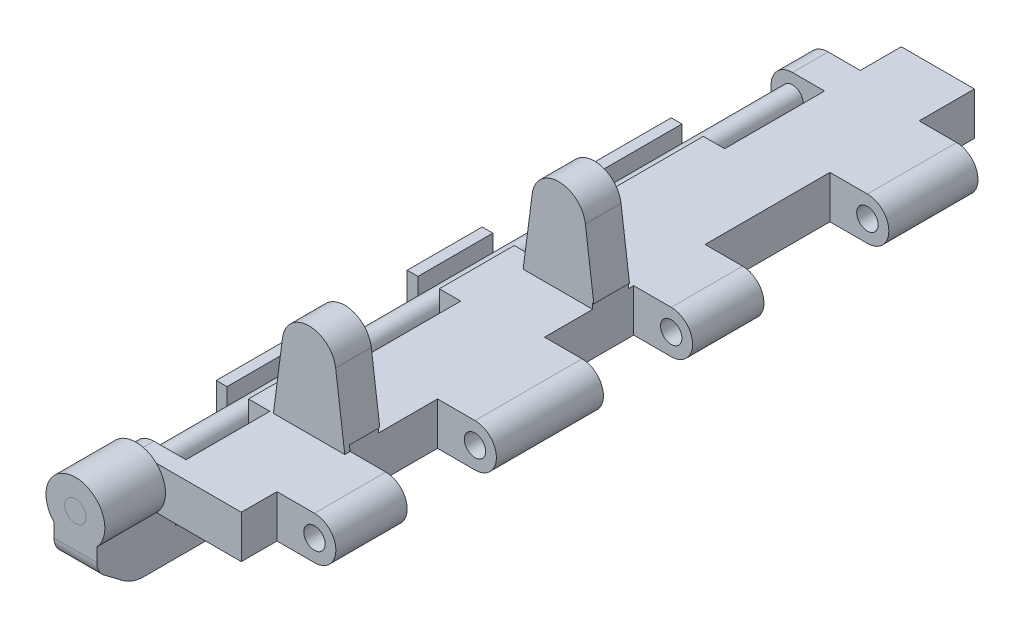
from build123d import *

# Parameters (mm, degrees)
SKETCH_1_R           = 0.6
EXTRUDE_1_DEPTH      = 41.1
SKETCH_2_W           = 5.7
SKETCH_2_H           = 5.25
SKETCH_2_W_2         = 12
SKETCH_2_W_3         = 19.4
CUT_EXTRUDE_1_DEPTH  = 9.75
CUT_EXTRUDE_START    = -1.2
SKETCH_6_W           = 4.7
SKETCH_6_H           = 3.5
SKETCH_6_W_2         = 6.5
SKETCH_6_W_3         = 4.6
SKETCH_6_W_4         = 5.6
SKETCH_6_W_5         = 2.3
CUT_EXTRUDE_4_DEPTH  = 3
CUT_EXTRUDE_5_DEPTH  = 3
CUT_EXTRUDE_START_2  = -36.8
CUT_EXTRUDE_6_DEPTH  = 3
CUT_EXTRUDE_START_3  = -5.7
SKETCH_11_W          = 1.2
SKETCH_11_H          = 1.2
CUT_EXTRUDE_7_DEPTH  = 27
SKETCH_12_W          = 3
SKETCH_12_H          = 4.320930259
SKETCH_12_W_2        = 2.5
CUT_EXTRUDE_8_DEPTH  = 3.5
SKETCH_13_W          = 3.3
SKETCH_13_H          = 2
SKETCH_13_H_2        = 5
SKETCH_13_H_3        = 7
SKETCH_13_H_4        = 3.1
CUT_EXTRUDE_9_DEPTH  = 1.5
SKETCH_14_R          = 1.65
SKETCH_14_R_2        = 0.6
EXTRUDE_2_DEPTH      = 3.4
CUT_EXTRUDE_10_DEPTH = 1.7
SKETCH_17_R          = 0.6
EXTRUDE_3_DEPTH      = 3.4
EXTRUDE_3_DEPTH_BACK = 38.8


with BuildPart() as part:
    # 草图1 → 凸台-拉伸1 (new body)
    with BuildSketch(Plane.XY):
        with BuildLine():
            Line((2, 1.2), (-1.2, 1.2))
            Line((-1.2, 1.2), (-1.2, -3.9))
            Line((-1.2, -3.9), (1.2, -3.9))
            Line((1.2, -3.9), (1.2, -1.2))
            Line((1.2, -1.2), (8, -1.2))
            ThreePointArc((8, -1.2), (9.2, 0), (8, 1.2))
            Line((8, 1.2), (6, 1.2))
            Line((6, 1.2), (5.487489304, 5.143327629))
            ThreePointArc((5.487489304, 5.143327629), (4, 6.45), (2.512510696, 5.143327629))
            Line((2.512510696, 5.143327629), (2, 1.2))
        make_face()
        Circle(SKETCH_1_R, mode=Mode.SUBTRACT)
        with Locations((8, 0)):
            Circle(SKETCH_1_R, mode=Mode.SUBTRACT)
    extrude(amount=-EXTRUDE_1_DEPTH)

    # 草图2 → 切除-拉伸1 (cut, symmetric)
    with BuildSketch(Plane(origin=(0, 0, 0), x_dir=(0, 0, -1), z_dir=(1, 0, 0))):
        with Locations((2.85, 3.825)):
            Rectangle(SKETCH_2_W, SKETCH_2_H)
        with Locations((13.7, 3.825)):
            Rectangle(SKETCH_2_W_2, SKETCH_2_H)
        with Locations((31.4, 3.825)):
            Rectangle(SKETCH_2_W_3, SKETCH_2_H)
    extrude(amount=CUT_EXTRUDE_1_DEPTH, both=True, mode=Mode.SUBTRACT)

    # 草图6 → 切除-拉伸4 (cut)
    with BuildSketch(Plane(origin=(0, 0, 0), x_dir=(0, 0, -1), z_dir=(1, 0, 0)).offset(CUT_EXTRUDE_START)):
        with Locations((3.35, -0.55)):
            Rectangle(SKETCH_6_W, SKETCH_6_H)
        with Locations((13.15, -0.55)):
            Rectangle(SKETCH_6_W_2, SKETCH_6_H)
        with Locations((22.9, -0.55)):
            Rectangle(SKETCH_6_W_3, SKETCH_6_H)
        with Locations((34, -0.55)):
            Rectangle(SKETCH_6_W_4, SKETCH_6_H)
        with Locations((39.95, -0.55)):
            Rectangle(SKETCH_6_W_5, SKETCH_6_H)
    extrude(amount=CUT_EXTRUDE_4_DEPTH, mode=Mode.SUBTRACT)

    # 草图9 → 切除-拉伸5 (cut)
    with BuildSketch(Plane.XY):
        with BuildLine():
            Line((0, 1.2), (-1.2, 1.2))
            Line((-1.2, 1.2), (-1.2, 0))
            ThreePointArc((-1.2, 0), (-0.848528137, 0.848528137), (0, 1.2))
        make_face()
    extrude(amount=-CUT_EXTRUDE_5_DEPTH, mode=Mode.SUBTRACT)

    # 草图9<3> → 切除-拉伸6 (cut)
    with BuildSketch(Plane.XY.offset(CUT_EXTRUDE_START_2)):
        with BuildLine():
            Line((0, 1.2), (-1.2, 1.2))
            Line((-1.2, 1.2), (-1.2, 0))
            ThreePointArc((-1.2, 0), (-0.848528137, 0.848528137), (0, 1.2))
        make_face()
    extrude(amount=-CUT_EXTRUDE_6_DEPTH, mode=Mode.SUBTRACT)

    # 草图11 → 切除-拉伸7 (cut)
    with BuildSketch(Plane.XY.offset(CUT_EXTRUDE_START_3)):
        with Locations((0, 0.6)):
            Rectangle(SKETCH_11_W, SKETCH_11_H)
    extrude(amount=-CUT_EXTRUDE_7_DEPTH, mode=Mode.SUBTRACT)

    # 草图12 → 切除-拉伸8 (cut, symmetric)
    with BuildSketch(Plane(origin=(0, 0, 0), x_dir=(0, 0, -1), z_dir=(1, 0, 0))):
        with Locations((28.2, -5.06046513)):
            Rectangle(SKETCH_12_W, SKETCH_12_H)
        with Locations((18.5, -5.06046513)):
            Rectangle(SKETCH_12_W_2, SKETCH_12_H)
        with Locations((7.8, -5.06046513)):
            Rectangle(SKETCH_12_W_2, SKETCH_12_H)
    extrude(amount=CUT_EXTRUDE_8_DEPTH, both=True, mode=Mode.SUBTRACT)

    # 草图13 → 切除-拉伸9 (cut, symmetric)
    with BuildSketch(Plane(origin=(0, 0, 0), x_dir=(1, 0, 0), z_dir=(0, 1, 0))):
        with Locations((7.55, 1)):
            Rectangle(SKETCH_13_W, SKETCH_13_H)
        with Locations((7.55, 8.5)):
            Rectangle(SKETCH_13_W, SKETCH_13_H_2)
        with Locations((7.55, 19.5)):
            Rectangle(SKETCH_13_W, SKETCH_13_H_2)
        with Locations((7.55, 29.5)):
            Rectangle(SKETCH_13_W, SKETCH_13_H_3)
        with Locations((7.55, 39.55)):
            Rectangle(SKETCH_13_W, SKETCH_13_H_4)
    extrude(amount=CUT_EXTRUDE_9_DEPTH, both=True, mode=Mode.SUBTRACT)

    # 草图14 → 凸台-拉伸2 (add)
    with BuildSketch(Plane.XY):
        Circle(SKETCH_14_R)
        Circle(SKETCH_14_R_2, mode=Mode.SUBTRACT)
        with BuildLine():
            ThreePointArc((1.2, -1.132475165), (0, -1.65), (-1.2, -1.132475165))
            Line((-1.2, -1.132475165), (-1.2, -3.9))
            Line((-1.2, -3.9), (1.2, -3.9))
            Line((1.2, -3.9), (1.2, -1.132475165))
        make_face()
    extrude(amount=EXTRUDE_2_DEPTH)

    # 草图15 → 切除-拉伸10 (cut, symmetric)
    with BuildSketch(Plane(origin=(0, 0, 0), x_dir=(0, 0, -1), z_dir=(1, 0, 0))):
        with BuildLine():
            ThreePointArc((-3.4, -1.9), (-3.294427191, -2.347213595), (-3, -2.7))
            Line((-3, -2.7), (-1.933333333, -3.5))
            ThreePointArc((-1.933333333, -3.5), (-1.365788865, -3.797366596), (-0.733333333, -3.9))
            Line((-0.733333333, -3.9), (-3.4, -3.9))
            Line((-3.4, -3.9), (-3.4, -1.9))
        make_face()
    extrude(amount=CUT_EXTRUDE_10_DEPTH, both=True, mode=Mode.SUBTRACT)


with BuildPart() as body_2:
    # 草图17 → 凸台-拉伸3 (new body, two sides)
    with BuildSketch(Plane.XY) as extrude_3_sk:
        Circle(SKETCH_17_R)
    extrude(amount=EXTRUDE_3_DEPTH)
    extrude(extrude_3_sk.sketch, amount=-EXTRUDE_3_DEPTH_BACK)


solid = Compound([part.part, body_2.part])
